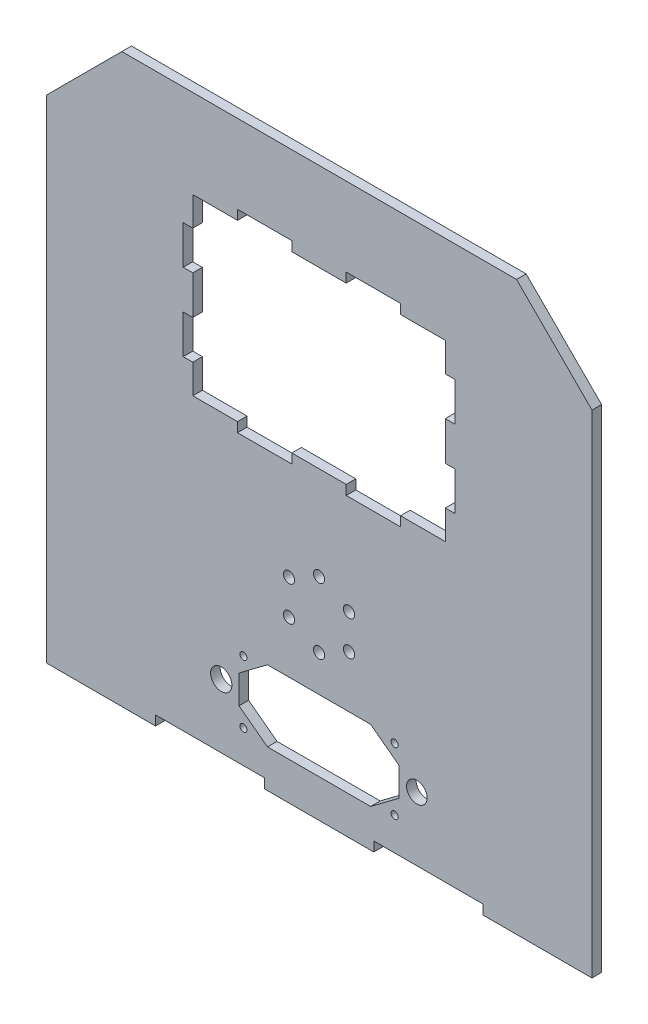
from build123d import *

# Parameters (mm, degrees)
SKETCH1_R           = 1
SKETCH1_R_2         = 3
SKETCH1_R_3         = 2.9
SKETCH1_R_4         = 1.575
BOSS_EXTRUDE3_DEPTH = 2.7


with BuildPart() as part:
    # Sketch1 → Boss-Extrude3 (new body)
    with BuildSketch(Plane.XY):
        Polygon((-45.972294428, -28.145904304), (-45.972294428, -25.445904304), (-15.292294428, -25.445904304), (-15.292294428, -28.145904304), (15.387705572, -28.145904304), (15.387705572, -25.445904304), (46.067705572, -25.445904304), (46.067705572, -28.145904304), (76.747705572, -28.145904304), (76.747705572, -25.445904304), (76.747705572, -23.145904304), (76.747705572, 12.854095696), (76.747705572, 110.140892261), (55.534502136, 131.354095696), (-55.439090993, 131.354095696), (-76.652294428, 110.140892261), (-76.652294428, 12.854095696), (-76.652294428, -23.145904304), (-76.652294428, -25.445904304), (-76.652294428, -28.145904304), align=None)
        with Locations((-21.25, -16.25)):
            Circle(SKETCH1_R, mode=Mode.SUBTRACT)
        with Locations((-27.5, -7.5)):
            Circle(SKETCH1_R_2, mode=Mode.SUBTRACT)
        with Locations((-21.25, 1.25)):
            Circle(SKETCH1_R, mode=Mode.SUBTRACT)
        with Locations((21.25, -16.25)):
            Circle(SKETCH1_R, mode=Mode.SUBTRACT)
        with Locations((27.5, -7.5)):
            Circle(SKETCH1_R_3, mode=Mode.SUBTRACT)
        with Locations((21.25, 1.25)):
            Circle(SKETCH1_R, mode=Mode.SUBTRACT)
        with Locations((0, 31.25)):
            Circle(SKETCH1_R_4, mode=Mode.SUBTRACT)
        with Locations((0, 12.75)):
            Circle(SKETCH1_R_4, mode=Mode.SUBTRACT)
        with Locations((-8.443747687, 17.125)):
            Circle(SKETCH1_R_4, mode=Mode.SUBTRACT)
        with Locations((-8.443747687, 26.875)):
            Circle(SKETCH1_R_4, mode=Mode.SUBTRACT)
        with Locations((8.443747687, 26.875)):
            Circle(SKETCH1_R_4, mode=Mode.SUBTRACT)
        with Locations((8.443747687, 17.125)):
            Circle(SKETCH1_R_4, mode=Mode.SUBTRACT)
        Polygon((-22.5, -3.5), (-14.5, 2.5), (14.5, 2.5), (22.5, -3.5), (22.5, -11.5), (14.5, -17.5), (0, -17.5), (-14.5, -17.5), (-22.5, -11.5), align=None, mode=Mode.SUBTRACT)
        Polygon((35.5, 57.5), (22.92, 57.5), (22.92, 54.8), (7.64, 54.8), (7.64, 57.5), (-7.64, 57.5), (-7.64, 54.8), (-22.92, 54.8), (-22.92, 57.5), (-35.5, 57.5), (-35.5, 65.68), (-38.2, 65.68), (-38.2, 76.56), (-35.5, 76.56), (-35.5, 87.44), (-38.2, 87.44), (-38.2, 98.32), (-35.5, 98.32), (-35.5, 106.5), (-22.92, 106.5), (-22.92, 109.2), (-7.64, 109.2), (-7.64, 106.5), (7.64, 106.5), (7.64, 109.2), (22.92, 109.2), (22.92, 106.5), (35.5, 106.5), (35.5, 98.32), (38.2, 98.32), (38.2, 87.44), (35.5, 87.44), (35.5, 76.56), (38.2, 76.56), (38.2, 65.68), (35.5, 65.68), align=None, mode=Mode.SUBTRACT)
    extrude(amount=BOSS_EXTRUDE3_DEPTH)


solid = part.part
